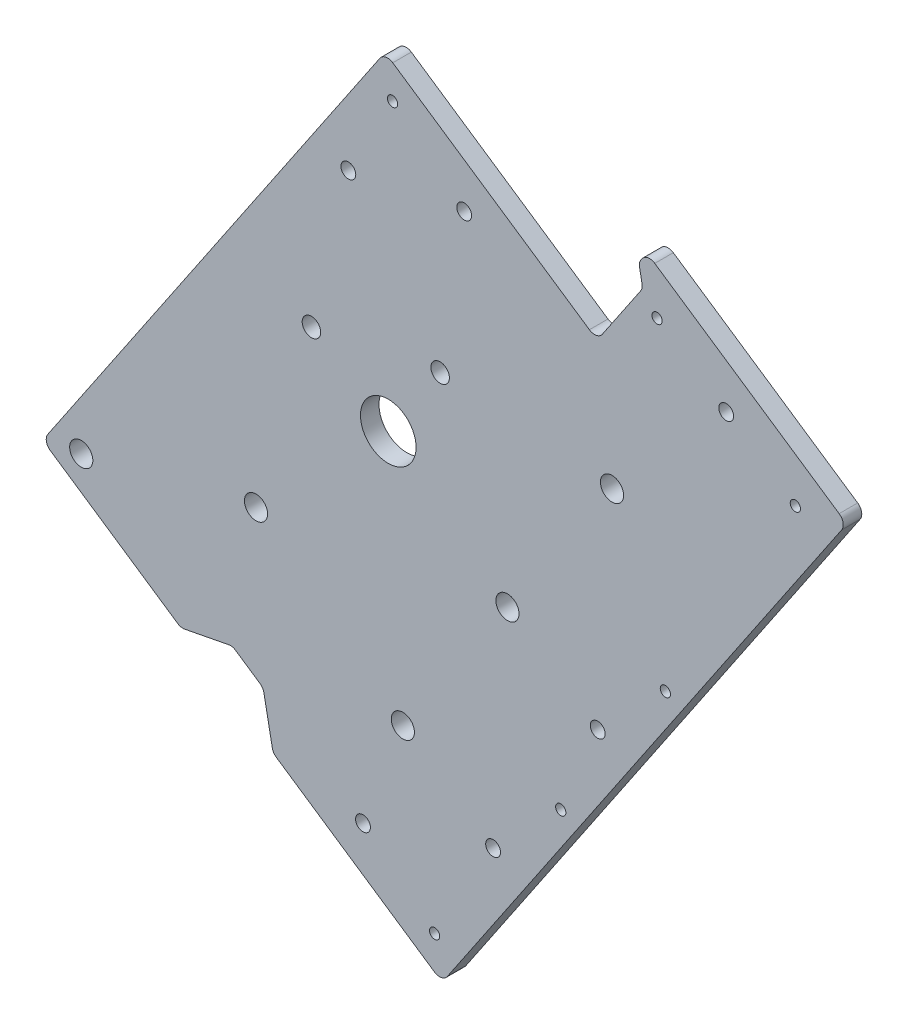
from build123d import *

# Parameters (mm, degrees)
BOSS_EXTRUDE2_DEPTH = 6.35
CUT_EXTRUDE1_DEPTH  = 7.3500001
BOSS_EXTRUDE3_DEPTH = 6.35
SKETCH10_R          = 3.96875
CUT_EXTRUDE2_DEPTH  = 7.35
SKETCH11_R          = 9.525
CUT_EXTRUDE4_DEPTH  = 7.35
BOSS_EXTRUDE4_DEPTH = 6.35
SKETCH13_R          = 1.75
CUT_EXTRUDE5_DEPTH  = 7.35
LPATTERN1_COUNT     = 2
LPATTERN1_PITCH     = 64
SKETCH14_R          = 2.54
CUT_EXTRUDE6_DEPTH  = 7.35
SKETCH15_R          = 1.75
CUT_EXTRUDE7_DEPTH  = 7.35
SKETCH16_R          = 1.75
CUT_EXTRUDE8_DEPTH  = 7.35
SKETCH17_R          = 1.75
CUT_EXTRUDE9_DEPTH  = 7.35
SKETCH19_R          = 3.96875
CUT_EXTRUDE11_DEPTH = 7.35
SKETCH21_R          = 2.54
CUT_EXTRUDE12_DEPTH = 7.35
SKETCH22_R          = 3.175
CUT_EXTRUDE13_DEPTH = 7.35
SKETCH23_R          = 3.96875
CUT_EXTRUDE14_DEPTH = 7.35
SKETCH24_R          = 4.285761756
SKETCH24_R_2        = 5.640780493
BOSS_EXTRUDE5_DEPTH = 6.35
CUT_EXTRUDE15_DEPTH = 7.35
FILLET1_R           = 3.175


with BuildPart() as part:
    # Sketch6 → Boss-Extrude2 (new body)
    with BuildSketch(Plane.XY):
        with BuildLine():
            Line((-68.006850091, -76.67090114), (-109.486767671, -48.656527855))
            Line((-109.486767671, -48.656527855), (-118.371760678, -61.812230963))
            Line((-118.371760678, -61.812230963), (18.447551645, -154.216158235))
            Line((18.447551645, -154.216158235), (135.729459338, 19.43912279))
            Line((135.729459338, 19.43912279), (-1.089852986, 111.843050063))
            Line((-1.089852986, 111.843050063), (-73.946795643, 3.966284577))
            Line((-73.946795643, 3.966284577), (-56.624438948, -7.732749433))
            ThreePointArc((-56.624438948, -7.732749433), (-43.058385537, 37.577891571), (0, 57.15))
            ThreePointArc((0, 57.15), (56.404848571, 31.095576642), (70.829334649, -29.338471048))
            add(Edge.make_bspline(
                [(70.829334649, -29.338471048), (70.811686062, -29.418295928), (70.776015112, -29.578104383), (70.713320217, -29.85478305), (70.619021771, -30.262929245), (70.501052001, -30.762086912), (70.364034474, -31.322191481), (70.199318515, -31.970958926), (70.000453855, -32.723919765), (69.795103485, -33.469783355), (69.582015398, -34.214296028), (69.361377803, -34.956693289), (69.133257682, -35.696762218), (68.838782679, -36.61892651), (68.470566207, -37.720710028), (68.019498024, -38.998776477), (67.474836154, -40.448808619), (66.901337925, -41.887676852), (66.299328392, -43.31485223), (65.669141732, -44.729810424), (65.011119088, -46.132040323), (64.325609411, -47.52103904), (63.612968547, -48.896314904), (62.87355937, -50.257385735), (62.107751613, -51.603779381), (61.315921169, -52.935034173), (60.49845004, -54.250698756), (59.655726138, -55.550331897), (58.571247582, -57.154294757), (57.220953058, -59.045283389), (55.576035723, -61.200397094), (53.604026134, -63.590264702), (51.54329346, -65.904053004), (49.39728314, -68.138962994), (47.169496434, -70.29235602), (44.863486103, -72.361752995), (42.482847363, -74.344831806), (40.031215607, -76.239428526), (36.882516177, -78.494556171), (32.976808929, -81.016011003), (28.250788286, -83.68089187), (21.41551215, -86.919136497), (14.30829026, -89.526654921), (6.996956895, -91.488176442), (-0.451922312, -92.797413176), (-6.61686174, -93.456358442), (-12.81195397, -93.702029749), (-19.009644204, -93.537285056), (-25.183124422, -92.966685286), (-31.306438312, -91.996382122), (-36.598524037, -90.804323442), (-41.072542301, -89.543185606), (-44.752319298, -88.33589156), (-47.664184976, -87.27761875), (-50.541347258, -86.128353728), (-53.381128552, -84.889612663), (-56.180924218, -83.562977818), (-58.593536599, -82.326710176), (-60.633378351, -81.214215821), (-62.313751085, -80.252471782), (-63.646071553, -79.462491566), (-64.966093336, -78.652178853), (-66.222359154, -77.854259082), (-67.143044791, -77.250601571), (-67.736251212, -76.85365602), (-68.006850091, -76.67090114)],
                knots=[0.071020771, 0.071020771, 0.071020771, 0.071020771, 0.071020771, 0.072848477, 0.074676184, 0.07650389, 0.078331597, 0.08198701, 0.085642423, 0.089297836, 0.092953249, 0.096608662, 0.100264075, 0.103919488, 0.107574901, 0.114885727, 0.122196554, 0.12950738, 0.136818214, 0.144129048, 0.151439882, 0.158750716, 0.166061558, 0.173372401, 0.180683243, 0.187994085, 0.195304924, 0.202615763, 0.209926602, 0.217237441, 0.231859103, 0.246480766, 0.261102426, 0.275724085, 0.290345754, 0.304967424, 0.319589099, 0.334210774, 0.348832457, 0.36345414, 0.392697464, 0.421940789, 0.451184112, 0.506140643, 0.535383973, 0.564627303, 0.593870641, 0.623113979, 0.652357319, 0.68160066, 0.710843985, 0.740087309, 0.754708984, 0.769330659, 0.783952333, 0.798574008, 0.813195669, 0.82781733, 0.842438991, 0.849749821, 0.857060652, 0.86437149, 0.871682327, 0.878993165, 0.885158103, 0.885158103, 0.885158103, 0.885158103, 0.885158103], degree=4))
        make_face()
    extrude(amount=BOSS_EXTRUDE2_DEPTH)

    # Sketch8 → Cut-Extrude1 (cut, through all)
    with BuildSketch(Plane.XY.offset(6.35)):
        Polygon((-71.011229489, -93.798205788), (-53.378672597, -90.381637707), (-42.854110111, -97.489632113), (-39.43754203, -115.122189004), align=None)
    extrude(amount=-CUT_EXTRUDE1_DEPTH, mode=Mode.SUBTRACT)

    # Sketch9 → Boss-Extrude3 (add, through all)
    with BuildSketch(Plane.XY.offset(6.35)):
        Polygon((-1.089852986, 111.843050063), (-109.486767671, -48.656527855), (27.332544652, -141.060455127), (135.729459338, 19.43912279), align=None)
    extrude(amount=-BOSS_EXTRUDE3_DEPTH)

    # Sketch10 → Cut-Extrude2 (cut, through all)
    with BuildSketch(Plane.XY.offset(6.35)):
        with Locations((4.996496209, -84.796642912)):
            Circle(SKETCH10_R)
        with Locations((40.816310536, -31.759477627)):
            Circle(SKETCH10_R)
        with Locations((76.636124864, 21.277687659)):
            Circle(SKETCH10_R)
        with Locations((-45.295165913, -45.214466102)):
            Circle(SKETCH10_R)
    extrude(amount=-CUT_EXTRUDE2_DEPTH, mode=Mode.SUBTRACT)

    # Sketch11 → Cut-Extrude4 (cut, through all)
    with BuildSketch(Plane.XY.offset(6.35)):
        Circle(SKETCH11_R)
    extrude(amount=-CUT_EXTRUDE4_DEPTH, mode=Mode.SUBTRACT)

    # Sketch12 → Boss-Extrude4 (add, through all)
    with BuildSketch(Plane.XY.offset(6.35)):
        Polygon((135.729459338, 19.43912279), (67.319803176, 65.641086427), (88.643786393, 97.214773886), (157.053442554, 51.01281025), align=None)
    extrude(amount=-BOSS_EXTRUDE4_DEPTH)

    # Sketch13 → Cut-Extrude5 (cut, through all)
    with BuildSketch(Plane.XY.offset(6.35)):
        with Locations((94.899221836, -29.671127724)):
            Circle(SKETCH13_R)
    cut_extrude5 = extrude(amount=-CUT_EXTRUDE5_DEPTH, mode=Mode.SUBTRACT)

    # LPattern1: Cut-Extrude5 ×2
    with Locations(*[Vector(-0.559684599, -0.828705708, 0) * (i * LPATTERN1_PITCH) for i in range(1, LPATTERN1_COUNT)]):
        add(cut_extrude5, mode=Mode.SUBTRACT)

    # Sketch14 → Cut-Extrude6 (cut, through all)
    with BuildSketch(Plane.XY.offset(6.35)):
        with Locations((71.72703343, -52.635713164)):
            Circle(SKETCH14_R)
        with Locations((35.907219102, -105.67287845)):
            Circle(SKETCH14_R)
        with Locations((115.740620068, 63.589229581)):
            Circle(SKETCH14_R)
    extrude(amount=-CUT_EXTRUDE6_DEPTH, mode=Mode.SUBTRACT)

    # Sketch15 → Cut-Extrude7 (cut, through all)
    with BuildSketch(Plane.XY.offset(6.35)):
        with Locations((-105.147343009, -59.249804902)):
            Circle(SKETCH15_R)
        with Locations((15.885125585, -140.991740566)):
            Circle(SKETCH15_R)
        with Locations((1.472573075, 98.618632394)):
            Circle(SKETCH15_R)
    extrude(amount=-CUT_EXTRUDE7_DEPTH, mode=Mode.SUBTRACT)

    # Sketch16 → Cut-Extrude8 (cut, through all)
    with BuildSketch(Plane.XY.offset(6.35)):
        with Locations((92.060354474, 79.582216994)):
            Circle(SKETCH16_R)
        with Locations((139.420885662, 47.596242169)):
            Circle(SKETCH16_R)
    extrude(amount=-CUT_EXTRUDE8_DEPTH, mode=Mode.SUBTRACT)

    # Sketch17 → Cut-Extrude9 (cut, through all)
    with BuildSketch(Plane.XY.offset(6.35)):
        with Locations((-26.311406216, 17.769986014)):
            Circle(SKETCH17_R)
        with Locations((17.769986014, 26.311406216)):
            Circle(SKETCH17_R)
    extrude(amount=-CUT_EXTRUDE9_DEPTH, mode=Mode.SUBTRACT)

    # Sketch19 → Cut-Extrude11 (cut, through all)
    with BuildSketch(Plane.XY.offset(6.35)):
        with Locations((-65.680233685, -85.904783923)):
            Circle(SKETCH19_R)
    extrude(amount=-CUT_EXTRUDE11_DEPTH, mode=Mode.SUBTRACT)

    # Sketch21 → Cut-Extrude12 (cut, through all)
    with BuildSketch(Plane.XY.offset(6.35)):
        with Locations((-13.666272317, 70.530227577)):
            Circle(SKETCH21_R)
        with Locations((26.00698069, 78.217505758)):
            Circle(SKETCH21_R)
        with Locations((-86.729358658, -71.688795112)):
            Circle(SKETCH21_R)
        with Locations((-8.64928203, -120.590613931)):
            Circle(SKETCH21_R)
    extrude(amount=-CUT_EXTRUDE12_DEPTH, mode=Mode.SUBTRACT)

    # Sketch22 → Cut-Extrude13 (cut, through all)
    with BuildSketch(Plane.XY.offset(6.35)):
        with Locations((-26.311406216, 17.769986014)):
            Circle(SKETCH22_R)
        with Locations((17.769986014, 26.311406216)):
            Circle(SKETCH22_R)
    extrude(amount=-CUT_EXTRUDE13_DEPTH, mode=Mode.SUBTRACT)

    # Sketch23 → Cut-Extrude14 (cut, through all)
    with BuildSketch(Plane.XY.offset(6.35)):
        with Locations((-105.147343009, -59.249804902)):
            Circle(SKETCH23_R)
    extrude(amount=-CUT_EXTRUDE14_DEPTH, mode=Mode.SUBTRACT)

    # Sketch24 → Boss-Extrude5 (add, through all)
    with BuildSketch(Plane.XY.offset(6.35)):
        with Locations((-86.729358658, -71.688795112)):
            Circle(SKETCH24_R)
        with Locations((-65.680233685, -85.904783923)):
            Circle(SKETCH24_R_2)
    extrude(amount=-BOSS_EXTRUDE5_DEPTH)

    # Sketch25 → Cut-Extrude15 (cut, through all)
    with BuildSketch(Plane.XY.offset(6.35)):
        Polygon((85.800588631, 93.004948891), (87.167215863, 85.951926135), (71.529628171, 62.797888664), (67.319803176, 65.641086427), align=None)
    extrude(amount=-CUT_EXTRUDE15_DEPTH, mode=Mode.SUBTRACT)

    # Fillet1
    fillet1_edges = [part.edges().sort_by_distance(p)[0] for p in [
        (-1.089852986, 111.843050063, 3.175),
        (18.447551645, -154.216158235, 3.175),
        (-118.371760678, -61.812230963, 3.175),
        (85.800588631, 93.004948891, 3.175),
        (87.167215863, 85.951926135, 3.175),
        (71.529628171, 62.797888664, 3.175),
        (-39.43754203, -115.122189004, 3.175),
        (-71.011229489, -93.798205788, 3.175),
        (-53.378672597, -90.381637707, 3.175),
        (-42.854110111, -97.489632113, 3.175),
        (157.053442554, 51.01281025, 3.175),
        (88.643786393, 97.214773886, 3.175),
    ]]
    fillet(fillet1_edges, radius=FILLET1_R)


solid = part.part
